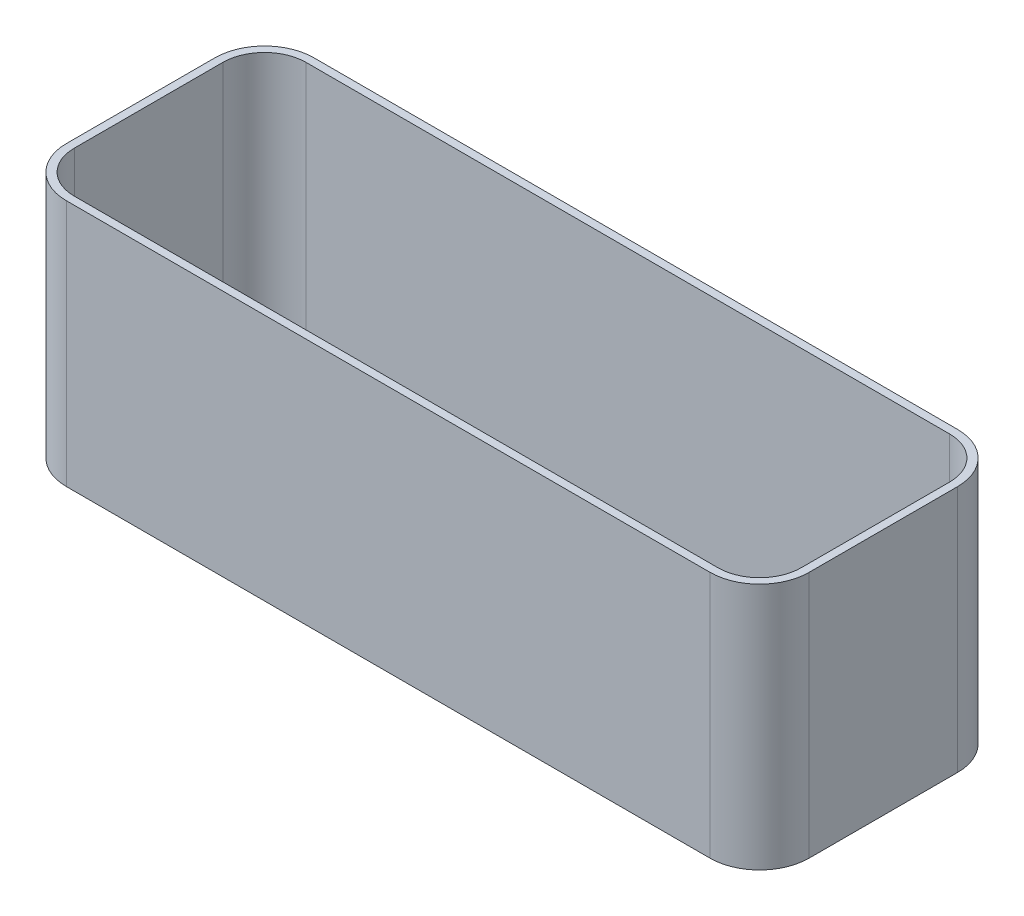
from build123d import *

# Parameters (mm, degrees)
EXTRUDE_1_DEPTH = 50
SHELL_1_T       = -1.6


with BuildPart() as part:
    # 草图1 → 凸台-拉伸1 (new body)
    with BuildSketch(Plane(origin=(0, 0, 0), x_dir=(1, 0, 0), z_dir=(0, 1, 0))):
        with BuildLine():
            Line((10, 0), (140, 0))
            ThreePointArc((140, 0), (147.071067812, 2.928932188), (150, 10))
            Line((150, 10), (150, 40))
            ThreePointArc((150, 40), (147.071067812, 47.071067812), (140, 50))
            Line((140, 50), (10, 50))
            ThreePointArc((10, 50), (2.928932188, 47.071067812), (0, 40))
            Line((0, 40), (0, 10))
            ThreePointArc((0, 10), (2.928932188, 2.928932188), (10, 0))
        make_face()
    extrude(amount=EXTRUDE_1_DEPTH)

    # 抽壳1
    shell_1_openings = [part.faces().sort_by_distance(p)[0] for p in [
        (75, 50, -25),
    ]]
    offset(amount=SHELL_1_T, openings=shell_1_openings, kind=Kind.INTERSECTION)


solid = part.part
